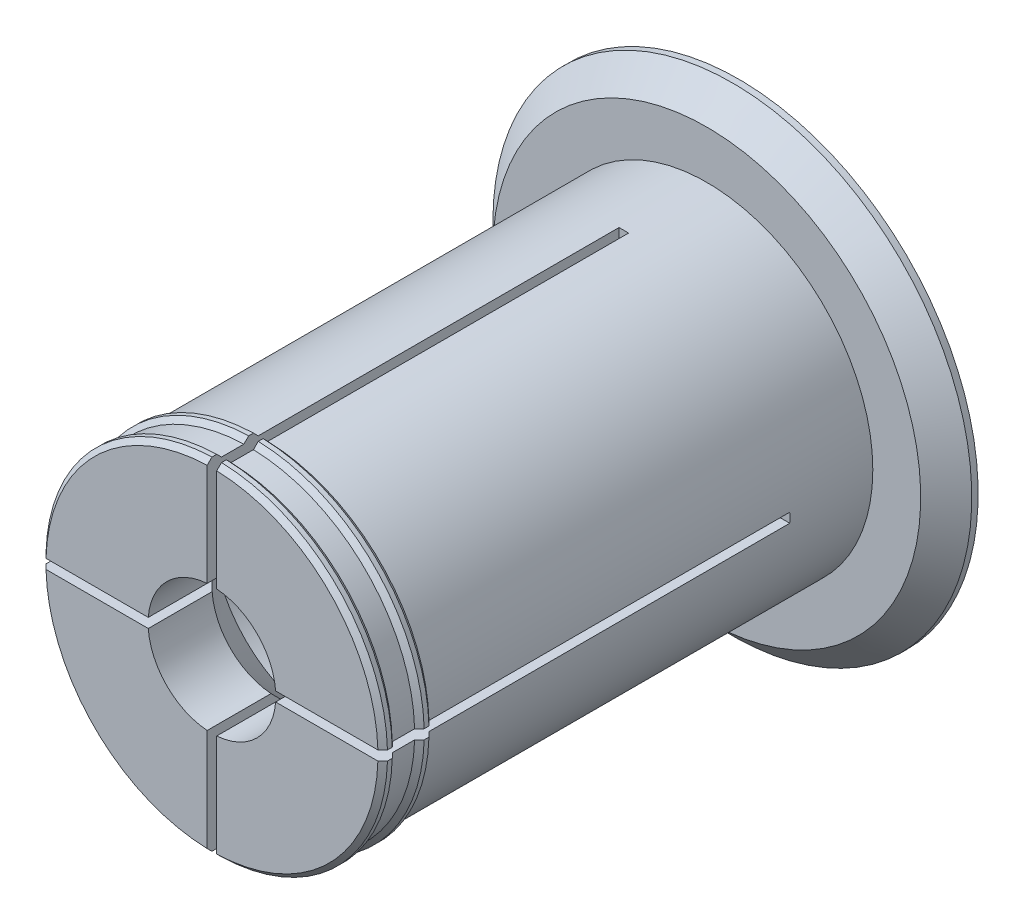
from build123d import *

# Parameters (mm, degrees)
AXLE_BASE_SKETCH_R        = 26
AXLE_DEPTH                = 77.5
GUARD_BASE_R              = 37.5
GUARD_DEPTH               = 5
INNER_AXLE_HOLE_BASE_R    = 10
INNER_AXLE_HOLE_DEPTH     = 83.5
BEND_START                = -64.5
BEND_ROOM_BASE_W          = 1.5
BEND_ROOM_BASE_H          = 75
BEND_ROOM_1_DEPTH         = 64.5
BEND_ROOM_2_COUNT         = 2
BEND_ROOM_2_ANGLE         = 90
EASY_REMOVAL_CHAMFER_SIZE = 4


with BuildPart() as part:
    # Axle base sketch → Axle (new body)
    with BuildSketch(Plane.XY):
        Circle(AXLE_BASE_SKETCH_R)
    extrude(amount=AXLE_DEPTH)

    # Guard base → Guard (add)
    with BuildSketch(Plane(origin=(0, 0, 0), x_dir=(-1, 0, 0), z_dir=(0, 0, -1))):
        Circle(GUARD_BASE_R)
    extrude(amount=GUARD_DEPTH)

    # Inner axle hole base → Inner axle hole (cut, through all)
    with BuildSketch(Plane.XY.offset(77.5)):
        Circle(INNER_AXLE_HOLE_BASE_R)
    extrude(amount=-INNER_AXLE_HOLE_DEPTH, mode=Mode.SUBTRACT)

    # Mate ring base → Mate rings (revolve)
    with BuildSketch(Plane(origin=(0, 0, 0), x_dir=(1, 0, 0), z_dir=(0, 1, 0))):
        Polygon((26, -77.5), (26.75, -76.75), (26.75, -76), (26, -75.25), align=None)
        Polygon((26, -71.75), (26.75, -71), (26.75, -70.25), (26, -69.5), align=None)
    revolve(axis=Axis((0, 0, 0), (0, 0, -1)))

    # Inner mass remove base → Inner mass remove (revolve, cut)
    with BuildSketch(Plane(origin=(0, 0, 0), x_dir=(0, 0, -1), z_dir=(1, 0, 0))):
        Polygon((-77.5, 0), (-59.5, -18), (-13, -18), (5, 0), align=None)
    revolve(axis=Axis((0, 0, 0), (0, 0, -1)), mode=Mode.SUBTRACT)

    # Bend room base → Bend room 1 (cut)
    with BuildSketch(Plane.XY.offset(77.5).offset(BEND_START)):
        Rectangle(BEND_ROOM_BASE_W, BEND_ROOM_BASE_H)
    bend_room_1 = extrude(amount=BEND_ROOM_1_DEPTH, mode=Mode.SUBTRACT)

    # Bend room 2: Bend room 1 ×2 about axis
    bend_room_2_axis = Axis((0, 0, 0), (0, 0, -1))
    for i in range(1, BEND_ROOM_2_COUNT):
        add(bend_room_1.rotate(bend_room_2_axis, i * BEND_ROOM_2_ANGLE / (BEND_ROOM_2_COUNT - 1)), mode=Mode.SUBTRACT)

    # Easy removal chamfer
    easy_removal_chamfer_edges = [part.edges().sort_by_distance(p)[0] for p in [
        (37.5, 0, 0),
    ]]
    chamfer(easy_removal_chamfer_edges, length=EASY_REMOVAL_CHAMFER_SIZE)


solid = part.part
